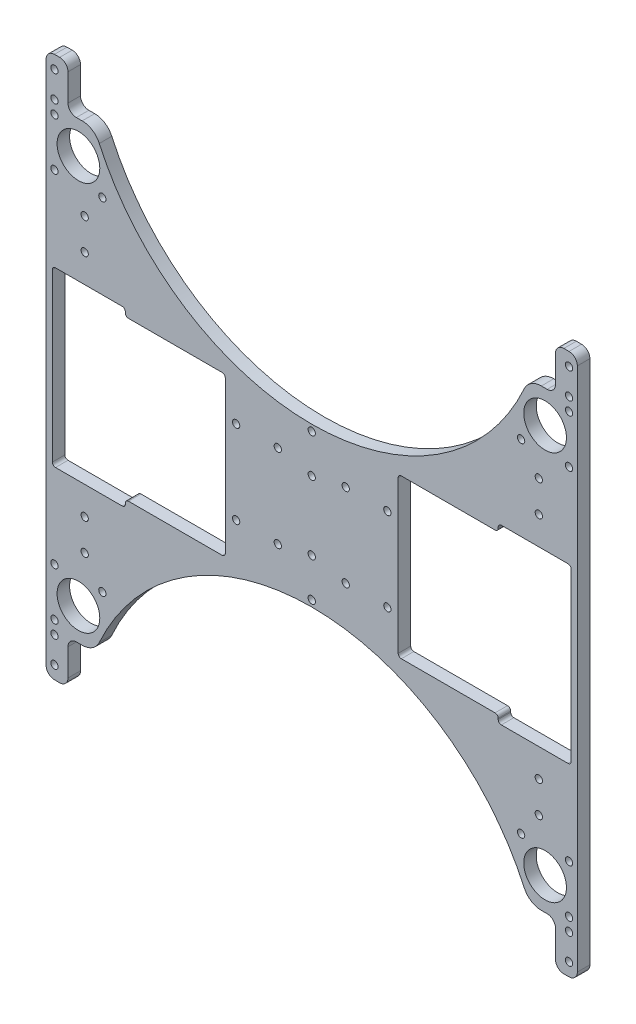
from build123d import *

# Parameters (mm, degrees)
ESQUISSE1_R        = 1.75
ESQUISSE1_R_2      = 10.25
BOSS_EXTRU_1_DEPTH = 6
CONG_1_R           = 4
CONG_2_R           = 1.5


with BuildPart() as part:
    # Esquisse1 → Boss.-Extru.1 (new body)
    with BuildSketch(Plane.XY):
        with BuildLine():
            Line((117, -130), (127.5, -130))
            Line((127.5, -130), (127.5, 130))
            Line((127.5, 130), (117, 130))
            Line((117, 130), (117, 109))
            Line((117, 109), (110.199818512, 109))
            ThreePointArc((110.199818512, 109), (105.313920853, 107.562324439), (101.985331022, 103.707535642))
            ThreePointArc((101.985331022, 103.707535642), (0, 38), (-101.985331022, 103.707535642))
            ThreePointArc((-101.985331022, 103.707535642), (-105.313920853, 107.562324439), (-110.199818512, 109))
            Line((-110.199818512, 109), (-117, 109))
            Line((-117, 109), (-117, 130))
            Line((-117, 130), (-127.5, 130))
            Line((-127.5, 130), (-127.5, -130))
            Line((-127.5, -130), (-117, -130))
            Line((-117, -130), (-117, -109))
            Line((-117, -109), (-110.199818512, -109))
            ThreePointArc((-110.199818512, -109), (-105.313920853, -107.562324439), (-101.985331022, -103.707535642))
            ThreePointArc((-101.985331022, -103.707535642), (0, -38), (101.985331022, -103.707535642))
            ThreePointArc((101.985331022, -103.707535642), (105.313920853, -107.562324439), (110.199818512, -109))
            Line((110.199818512, -109), (117, -109))
            Line((117, -109), (117, -130))
        make_face()
        with Locations((-123.5, -123.75)):
            Circle(ESQUISSE1_R, mode=Mode.SUBTRACT)
        with Locations((-123.5, -111.25)):
            Circle(ESQUISSE1_R, mode=Mode.SUBTRACT)
        with Locations((-123.5, -105)):
            Circle(ESQUISSE1_R, mode=Mode.SUBTRACT)
        with Locations((-112, -93.5)):
            Circle(ESQUISSE1_R_2, mode=Mode.SUBTRACT)
        with Locations((-123.5, -82)):
            Circle(ESQUISSE1_R, mode=Mode.SUBTRACT)
        with Locations((-100.5, -82)):
            Circle(ESQUISSE1_R, mode=Mode.SUBTRACT)
        with Locations((-109, -70)):
            Circle(ESQUISSE1_R, mode=Mode.SUBTRACT)
        with Locations((-109, -55)):
            Circle(ESQUISSE1_R, mode=Mode.SUBTRACT)
        with Locations((-36.3, -20)):
            Circle(ESQUISSE1_R, mode=Mode.SUBTRACT)
        with Locations((-16.3, -20)):
            Circle(ESQUISSE1_R, mode=Mode.SUBTRACT)
        with Locations((123.5, -123.75)):
            Circle(ESQUISSE1_R, mode=Mode.SUBTRACT)
        with Locations((123.5, -111.25)):
            Circle(ESQUISSE1_R, mode=Mode.SUBTRACT)
        with Locations((123.5, -105)):
            Circle(ESQUISSE1_R, mode=Mode.SUBTRACT)
        with Locations((100.5, -82)):
            Circle(ESQUISSE1_R, mode=Mode.SUBTRACT)
        with Locations((112, -93.5)):
            Circle(ESQUISSE1_R_2, mode=Mode.SUBTRACT)
        with Locations((123.5, -82)):
            Circle(ESQUISSE1_R, mode=Mode.SUBTRACT)
        with Locations((109, -70)):
            Circle(ESQUISSE1_R, mode=Mode.SUBTRACT)
        with Locations((0, -35)):
            Circle(ESQUISSE1_R, mode=Mode.SUBTRACT)
        with Locations((0, -16.5)):
            Circle(ESQUISSE1_R, mode=Mode.SUBTRACT)
        with Locations((16.3, -20)):
            Circle(ESQUISSE1_R, mode=Mode.SUBTRACT)
        with Locations((36.3, -20)):
            Circle(ESQUISSE1_R, mode=Mode.SUBTRACT)
        with Locations((109, -55)):
            Circle(ESQUISSE1_R, mode=Mode.SUBTRACT)
        Polygon((-89.5, 38), (-41.5, 38), (-41.5, -38), (-89.5, -38), (-89.5, -41.5), (-124.5, -41.5), (-124.5, 41.5), (-89.5, 41.5), align=None, mode=Mode.SUBTRACT)
        with Locations((-109, 55)):
            Circle(ESQUISSE1_R, mode=Mode.SUBTRACT)
        with Locations((-36.3, 20)):
            Circle(ESQUISSE1_R, mode=Mode.SUBTRACT)
        with Locations((-16.3, 20)):
            Circle(ESQUISSE1_R, mode=Mode.SUBTRACT)
        with Locations((0, 35)):
            Circle(ESQUISSE1_R, mode=Mode.SUBTRACT)
        with Locations((-109, 70)):
            Circle(ESQUISSE1_R, mode=Mode.SUBTRACT)
        with Locations((-123.5, 82)):
            Circle(ESQUISSE1_R, mode=Mode.SUBTRACT)
        with Locations((-112, 93.5)):
            Circle(ESQUISSE1_R_2, mode=Mode.SUBTRACT)
        with Locations((-100.5, 82)):
            Circle(ESQUISSE1_R, mode=Mode.SUBTRACT)
        with Locations((-123.5, 105)):
            Circle(ESQUISSE1_R, mode=Mode.SUBTRACT)
        with Locations((-123.5, 111.25)):
            Circle(ESQUISSE1_R, mode=Mode.SUBTRACT)
        with Locations((-123.5, 123.75)):
            Circle(ESQUISSE1_R, mode=Mode.SUBTRACT)
        with Locations((0, 16.5)):
            Circle(ESQUISSE1_R, mode=Mode.SUBTRACT)
        with Locations((16.3, 20)):
            Circle(ESQUISSE1_R, mode=Mode.SUBTRACT)
        with Locations((36.3, 20)):
            Circle(ESQUISSE1_R, mode=Mode.SUBTRACT)
        Polygon((41.5, 38), (89.5, 38), (89.5, 41.5), (124.5, 41.5), (124.5, -41.5), (89.5, -41.5), (89.5, -38), (41.5, -38), align=None, mode=Mode.SUBTRACT)
        with Locations((109, 55)):
            Circle(ESQUISSE1_R, mode=Mode.SUBTRACT)
        with Locations((109, 70)):
            Circle(ESQUISSE1_R, mode=Mode.SUBTRACT)
        with Locations((100.5, 82)):
            Circle(ESQUISSE1_R, mode=Mode.SUBTRACT)
        with Locations((123.5, 82)):
            Circle(ESQUISSE1_R, mode=Mode.SUBTRACT)
        with Locations((112, 93.5)):
            Circle(ESQUISSE1_R_2, mode=Mode.SUBTRACT)
        with Locations((123.5, 105)):
            Circle(ESQUISSE1_R, mode=Mode.SUBTRACT)
        with Locations((123.5, 111.25)):
            Circle(ESQUISSE1_R, mode=Mode.SUBTRACT)
        with Locations((123.5, 123.75)):
            Circle(ESQUISSE1_R, mode=Mode.SUBTRACT)
    extrude(amount=BOSS_EXTRU_1_DEPTH)

    # Congé1
    cong_1_edges = [part.edges().sort_by_distance(p)[0] for p in [
        (-117, -109, 3),
        (-117, -130, 3),
        (-127.5, -130, 3),
        (-127.5, 130, 3),
        (-117, 130, 3),
        (-117, 109, 3),
        (117, 109, 3),
        (117, 130, 3),
        (127.5, 130, 3),
        (127.5, -130, 3),
        (117, -130, 3),
        (117, -109, 3),
    ]]
    fillet(cong_1_edges, radius=CONG_1_R)

    # Congé2
    cong_2_edges = [part.edges().sort_by_distance(p)[0] for p in [
        (41.5, -38, 3),
        (89.5, -38, 3),
        (89.5, -41.5, 3),
        (124.5, -41.5, 3),
        (124.5, 41.5, 3),
        (89.5, 41.5, 3),
        (89.5, 38, 3),
        (41.5, 38, 3),
        (-89.5, 41.5, 3),
        (-124.5, 41.5, 3),
        (-124.5, -41.5, 3),
        (-89.5, -41.5, 3),
        (-89.5, -38, 3),
        (-41.5, -38, 3),
        (-41.5, 38, 3),
        (-89.5, 38, 3),
    ]]
    fillet(cong_2_edges, radius=CONG_2_R)


solid = part.part
